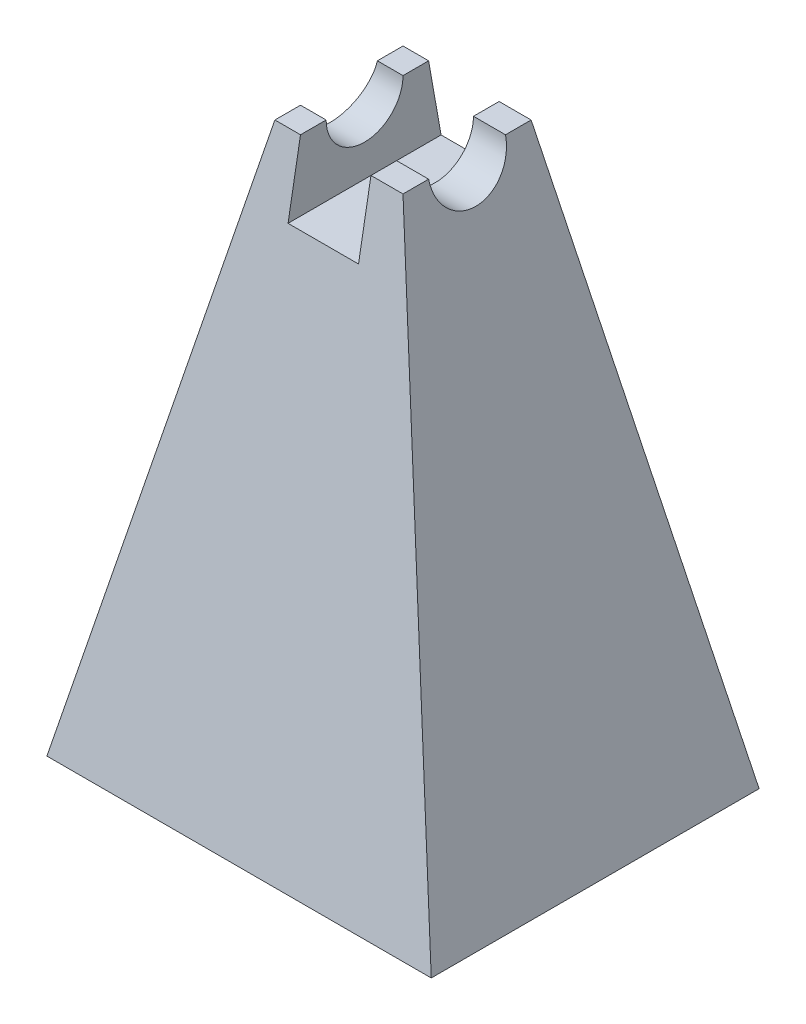
from build123d import *

# Parameters (mm, degrees)
BOSS_EXTRUDE1_DEPTH     = 65.000000048
CUT_EXTRUDE1_DEPTH      = 39.1
CUT_EXTRUDE1_DEPTH_BACK = 39.1
SKETCH4_W               = 13.97
SKETCH4_H               = 13.97
CUT_EXTRUDE2_DEPTH      = 1
CUT_EXTRUDE2_DEPTH_BACK = 66.000000048
CUT_EXTRUDE4_DEPTH      = 39.1
CUT_EXTRUDE4_DEPTH_BACK = 39.1


with BuildPart() as part:
    # Sketch2 → Boss-Extrude1 (new body)
    with BuildSketch(Plane.XY):
        Polygon((-38.1, -56.007), (-12.7, 56.007), (12.7, 56.007), (38.1, -56.007), align=None)
    extrude(amount=-BOSS_EXTRUDE1_DEPTH)

    # Sketch3 → Cut-Extrude1 (cut, two sides)
    with BuildSketch(Plane(origin=(0, 0, 0), x_dir=(0, 0, -1), z_dir=(1, 0, 0))) as cut_extrude1_sk:
        Polygon((0, -56.007), (19.800000024, 56.007), (0, 56.007), align=None)
        Polygon((65.000000048, -56.007), (45.200000024, 56.007), (65.000000048, 56.007), align=None)
    extrude(amount=CUT_EXTRUDE1_DEPTH, mode=Mode.SUBTRACT)
    extrude(cut_extrude1_sk.sketch, amount=-CUT_EXTRUDE1_DEPTH_BACK, mode=Mode.SUBTRACT)

    # Sketch4 → Cut-Extrude2 (cut, two sides)
    with BuildSketch(Plane.XY) as cut_extrude2_sk:
        with Locations((-0.635, 49.022)):
            Rectangle(SKETCH4_W, SKETCH4_H)
    extrude(amount=CUT_EXTRUDE2_DEPTH, mode=Mode.SUBTRACT)
    extrude(cut_extrude2_sk.sketch, amount=-CUT_EXTRUDE2_DEPTH_BACK, mode=Mode.SUBTRACT)

    # Sketch5 → Cut-Extrude4 (cut, two sides)
    with BuildSketch(Plane(origin=(0, 0, 0), x_dir=(0, 0, -1), z_dir=(1, 0, 0))) as cut_extrude4_sk:
        with BuildLine():
            Line((40.120000024, 56.007), (24.880000024, 56.007))
            ThreePointArc((24.880000024, 56.007), (32.500000024, 48.387), (40.120000024, 56.007))
        make_face()
    extrude(amount=CUT_EXTRUDE4_DEPTH, mode=Mode.SUBTRACT)
    extrude(cut_extrude4_sk.sketch, amount=-CUT_EXTRUDE4_DEPTH_BACK, mode=Mode.SUBTRACT)


solid = part.part
